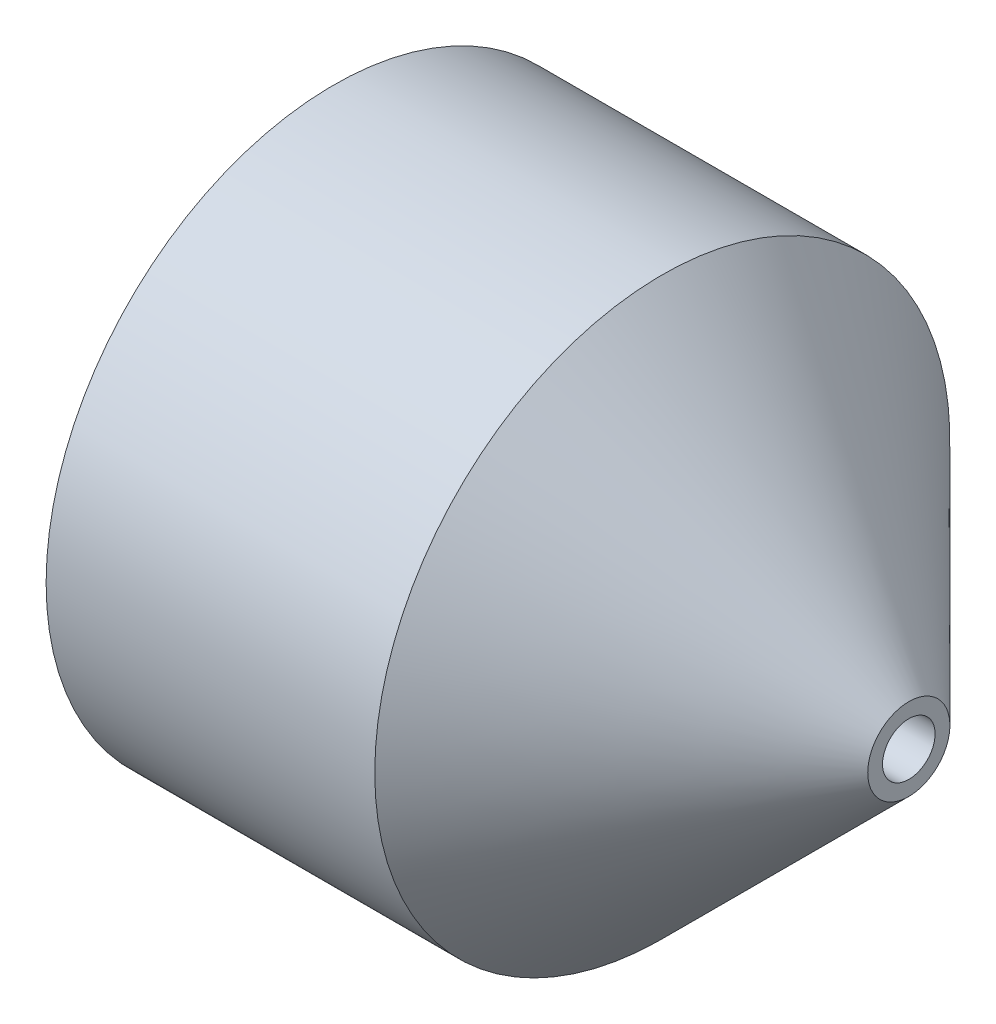
from build123d import *


with BuildPart() as part:
    # Sketch1 → Revolve1 (revolve)
    with BuildSketch(Plane.XY):
        Polygon((35, 1.6), (35, 2.5), (20, 17.5), (0, 17.5), (0, 11.75), (12.85, 11.75), (23, 1.6), align=None)
    revolve(axis=Axis((-79.434030099, 0, 0), (1, 0, 0)))


solid = part.part
